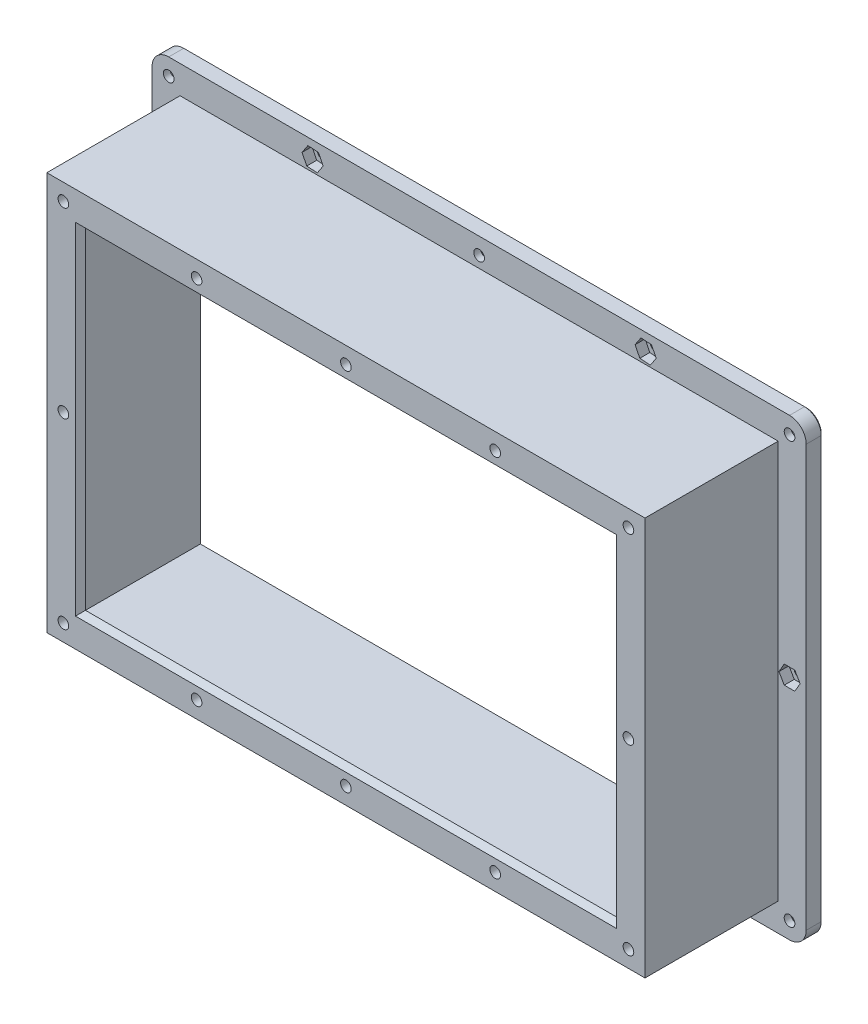
from build123d import *

# Parameters (mm, degrees)
CROQUIS1_W              = 179.6
CROQUIS1_H              = 119.6
CROQUIS1_W_2            = 176.4
CROQUIS1_H_2            = 116.4
SALIENTE_EXTRUIR1_DEPTH = 40
CROQUIS2_W              = 196.4
CROQUIS2_H              = 136.4
CROQUIS2_W_2            = 176.4
CROQUIS2_H_2            = 116.4
SALIENTE_EXTRUIR2_DEPTH = 5
SALIENTE_EXTRUIR3_DEPTH = 116.4
SALIENTE_EXTRUIR4_DEPTH = 176.4
CROQUIS5_R              = 1.6
CORTAR_EXTRUIR1_DEPTH   = 46
CORTAR_EXTRUIR2_START   = -3
CORTAR_EXTRUIR2_DEPTH   = 43
CHAFL_N1_SIZE2          = 2.121320344
CHAFL_N1_SIZE           = 3
CHAFL_N1_EDGE_2_SIZE2   = 2.121320344
CHAFL_N1_EDGE_2_SIZE    = 3
CHAFL_N1_EDGE_3_SIZE2   = 2.121320344
CHAFL_N1_EDGE_3_SIZE    = 3
CHAFL_N1_EDGE_4_SIZE2   = 2.121320344
CHAFL_N1_EDGE_4_SIZE    = 3
CROQUIS7_R              = 1.6
CORTAR_EXTRUIR3_DEPTH   = 46
CROQUIS8_R              = 2.75
CORTAR_EXTRUIR4_DEPTH   = 3
CORTAR_EXTRUIR5_START   = -2
CORTAR_EXTRUIR5_DEPTH   = 44
REDONDEO1_R             = 5
CHAFL_N2_SIZE           = 0.5


with BuildPart() as part:
    # Croquis1 → Saliente-Extruir1 (new body)
    with BuildSketch(Plane.XY):
        Rectangle(CROQUIS1_W, CROQUIS1_H)
        Rectangle(CROQUIS1_W_2, CROQUIS1_H_2, mode=Mode.SUBTRACT)
    extrude(amount=SALIENTE_EXTRUIR1_DEPTH)

    # Croquis2 → Saliente-Extruir2 (add)
    with BuildSketch(Plane(origin=(0, 0, 0), x_dir=(-1, 0, 0), z_dir=(0, 0, -1))):
        Rectangle(CROQUIS2_W, CROQUIS2_H)
        Rectangle(CROQUIS2_W_2, CROQUIS2_H_2, mode=Mode.SUBTRACT)
    extrude(amount=SALIENTE_EXTRUIR2_DEPTH)

    # Croquis3 → Saliente-Extruir3 (add)
    with BuildSketch(Plane.XZ.offset(-58.2)):
        Polygon((-88.2, 30), (-78.2, 40), (-88.2, 40), align=None)
        Polygon((88.2, 40), (88.2, 30), (78.2, 40), align=None)
    extrude(amount=SALIENTE_EXTRUIR3_DEPTH)

    # Croquis4 → Saliente-Extruir4 (add)
    with BuildSketch(Plane(origin=(-88.2, 0, 0), x_dir=(0, 0, -1), z_dir=(1, 0, 0))):
        Polygon((-40, 58.2), (-30, 58.2), (-40, 48.2), align=None)
        Polygon((-40, -48.2), (-40, -58.2), (-30, -58.2), align=None)
    extrude(amount=SALIENTE_EXTRUIR4_DEPTH)

    # Croquis5 → Cortar-Extruir1 (cut, through all)
    with BuildSketch(Plane.XY.offset(40)):
        with Locations((-84.827346257, 54.8)):
            Circle(CROQUIS5_R)
        with Locations((0, 54.8)):
            Circle(CROQUIS5_R)
        with Locations((-44.827346257, 54.8)):
            Circle(CROQUIS5_R)
        with Locations((44.827346257, 54.8)):
            Circle(CROQUIS5_R)
        with Locations((84.827346257, 54.8)):
            Circle(CROQUIS5_R)
        with Locations((84.827346257, -54.8)):
            Circle(CROQUIS5_R)
        with Locations((44.827346257, -54.8)):
            Circle(CROQUIS5_R)
        with Locations((-44.827346257, -54.8)):
            Circle(CROQUIS5_R)
        with Locations((0, -54.8)):
            Circle(CROQUIS5_R)
        with Locations((-84.827346257, -54.8)):
            Circle(CROQUIS5_R)
        with Locations((-84.827346257, 0)):
            Circle(CROQUIS5_R)
        with Locations((84.827346257, 0)):
            Circle(CROQUIS5_R)
    extrude(amount=-CORTAR_EXTRUIR1_DEPTH, mode=Mode.SUBTRACT)

    # Croquis6 → Cortar-Extruir2 (cut, through all)
    with BuildSketch(Plane.XY.offset(40).offset(CORTAR_EXTRUIR2_START)):
        Polygon((3.175426481, 54.8), (1.58771324, 57.55), (-1.58771324, 57.55), (-3.175426481, 54.8), (-1.58771324, 52.05), (1.58771324, 52.05), align=None)
        Polygon((-41.651919776, 54.8), (-43.239633017, 57.55), (-46.415059497, 57.55), (-48.002772737, 54.8), (-46.415059497, 52.05), (-43.239633017, 52.05), align=None)
        Polygon((-81.651919776, 54.8), (-83.239633017, 57.55), (-86.415059497, 57.55), (-88.002772737, 54.8), (-86.415059497, 52.05), (-83.239633017, 52.05), align=None)
        Polygon((48.002772737, 54.8), (46.415059497, 57.55), (43.239633017, 57.55), (41.651919776, 54.8), (43.239633017, 52.05), (46.415059497, 52.05), align=None)
        Polygon((88.002772737, 54.8), (86.415059497, 57.55), (83.239633017, 57.55), (81.651919776, 54.8), (83.239633017, 52.05), (86.415059497, 52.05), align=None)
        Polygon((86.415059497, -52.05), (88.002772737, -54.8), (86.415059497, -57.55), (83.239633017, -57.55), (81.651919776, -54.8), (83.239633017, -52.05), align=None)
        Polygon((46.415059497, -52.05), (48.002772737, -54.8), (46.415059497, -57.55), (43.239633017, -57.55), (41.651919776, -54.8), (43.239633017, -52.05), align=None)
        Polygon((-83.239633017, -52.05), (-81.651919776, -54.8), (-83.239633017, -57.55), (-86.415059497, -57.55), (-88.002772737, -54.8), (-86.415059497, -52.05), align=None)
        Polygon((-43.239633017, -52.05), (-41.651919776, -54.8), (-43.239633017, -57.55), (-46.415059497, -57.55), (-48.002772737, -54.8), (-46.415059497, -52.05), align=None)
        Polygon((1.58771324, -52.05), (3.175426481, -54.8), (1.58771324, -57.55), (-1.58771324, -57.55), (-3.175426481, -54.8), (-1.58771324, -52.05), align=None)
        Polygon((-81.651919776, 0), (-83.239633017, 2.75), (-86.415059497, 2.75), (-88.002772737, 0), (-86.415059497, -2.75), (-83.239633017, -2.75), align=None)
        Polygon((88.002772737, 0), (86.415059497, 2.75), (83.239633017, 2.75), (81.651919776, 0), (83.239633017, -2.75), (86.415059497, -2.75), align=None)
    extrude(amount=-CORTAR_EXTRUIR2_DEPTH, mode=Mode.SUBTRACT)

    # Chaflán1
    chafl_n1_edges = [part.edges().sort_by_distance(p)[0] for p in [
        (0, 48.2, 40),
    ]]
    chamfer(chafl_n1_edges, length=CHAFL_N1_SIZE, length2=CHAFL_N1_SIZE2)

    # Chaflán1 edge 2
    chafl_n1_edge_2_edges = [part.edges().sort_by_distance(p)[0] for p in [
        (78.2, 0, 40),
    ]]
    chamfer(chafl_n1_edge_2_edges, length=CHAFL_N1_EDGE_2_SIZE, length2=CHAFL_N1_EDGE_2_SIZE2)

    # Chaflán1 edge 3
    chafl_n1_edge_3_edges = [part.edges().sort_by_distance(p)[0] for p in [
        (-78.2, 0, 40),
    ]]
    chamfer(chafl_n1_edge_3_edges, length=CHAFL_N1_EDGE_3_SIZE, length2=CHAFL_N1_EDGE_3_SIZE2)

    # Chaflán1 edge 4
    chafl_n1_edge_4_edges = [part.edges().sort_by_distance(p)[0] for p in [
        (0, -48.2, 40),
    ]]
    chamfer(chafl_n1_edge_4_edges, length=CHAFL_N1_EDGE_4_SIZE, length2=CHAFL_N1_EDGE_4_SIZE2)

    # Croquis7 → Cortar-Extruir3 (cut, through all)
    with BuildSketch(Plane(origin=(0, 0, -5), x_dir=(-1, 0, 0), z_dir=(0, 0, -1))):
        with Locations((0, 63.2)):
            Circle(CROQUIS7_R)
        with Locations((93.2, 63.2)):
            Circle(CROQUIS7_R)
        with Locations((93.2, 0)):
            Circle(CROQUIS7_R)
        with Locations((50, 63.2)):
            Circle(CROQUIS7_R)
        with Locations((-50, 63.2)):
            Circle(CROQUIS7_R)
        with Locations((-93.2, 63.2)):
            Circle(CROQUIS7_R)
        with Locations((-93.2, 0)):
            Circle(CROQUIS7_R)
        with Locations((-93.2, -63.2)):
            Circle(CROQUIS7_R)
        with Locations((-50, -63.2)):
            Circle(CROQUIS7_R)
        with Locations((50, -63.2)):
            Circle(CROQUIS7_R)
        with Locations((93.2, -63.2)):
            Circle(CROQUIS7_R)
        with Locations((0, -63.2)):
            Circle(CROQUIS7_R)
    extrude(amount=-CORTAR_EXTRUIR3_DEPTH, mode=Mode.SUBTRACT)

    # Croquis8 → Cortar-Extruir4 (cut)
    with BuildSketch(Plane(origin=(0, 0, -5), x_dir=(-1, 0, 0), z_dir=(0, 0, -1))):
        with Locations((-93.2, 63.2)):
            Circle(CROQUIS8_R)
        with Locations((0, 63.2)):
            Circle(CROQUIS8_R)
        with Locations((93.2, 63.2)):
            Circle(CROQUIS8_R)
        with Locations((93.2, -63.2)):
            Circle(CROQUIS8_R)
        with Locations((0, -63.2)):
            Circle(CROQUIS8_R)
        with Locations((-93.2, -63.2)):
            Circle(CROQUIS8_R)
    extrude(amount=-CORTAR_EXTRUIR4_DEPTH, mode=Mode.SUBTRACT)

    # Croquis9 → Cortar-Extruir5 (cut, through all)
    with BuildSketch(Plane(origin=(0, 0, -5), x_dir=(-1, 0, 0), z_dir=(0, 0, -1)).offset(CORTAR_EXTRUIR5_START)):
        Polygon((-46.830853209, 63.399604482), (-48.588289157, 66.044363871), (-51.757435948, 65.844759388), (-53.169146791, 63.000395518), (-51.411710843, 60.355636129), (-48.242564052, 60.555240612), align=None)
        Polygon((53.169146791, 63.399604482), (51.411710843, 66.044363871), (48.242564052, 65.844759388), (46.830853209, 63.000395518), (48.588289157, 60.355636129), (51.757435948, 60.555240612), align=None)
        Polygon((53.169146791, -63.399604482), (51.757435948, -60.555240612), (48.588289157, -60.355636129), (46.830853209, -63.000395518), (48.242564052, -65.844759388), (51.411710843, -66.044363871), align=None)
        Polygon((-46.96440699, -62.268062012), (-49.289285467, -60.105130344), (-52.324878477, -61.037068332), (-53.03559301, -64.131937988), (-50.710714533, -66.294869656), (-47.675121523, -65.362931668), align=None)
        Polygon((96.375426481, 0), (94.78771324, 2.75), (91.61228676, 2.75), (90.024573519, 0), (91.61228676, -2.75), (94.78771324, -2.75), align=None)
        Polygon((-90.024573519, 0), (-91.61228676, 2.75), (-94.78771324, 2.75), (-96.375426481, 0), (-94.78771324, -2.75), (-91.61228676, -2.75), align=None)
    extrude(amount=-CORTAR_EXTRUIR5_DEPTH, mode=Mode.SUBTRACT)

    # Redondeo1
    redondeo1_edges = [part.edges().sort_by_distance(p)[0] for p in [
        (-98.2, -68.2, -2.5),
        (-98.2, 68.2, -2.5),
        (98.2, 68.2, -2.5),
        (98.2, -68.2, -2.5),
    ]]
    fillet(redondeo1_edges, radius=REDONDEO1_R)

    # Chaflán2
    chafl_n2_edges = [part.edges().sort_by_distance(p)[0] for p in [
        (-88.2, 0, -5),
        (0, 58.2, -5),
        (88.2, 0, -5),
        (0, -58.2, -5),
        (51.6, -63.2, -5),
        (94.8, 0, -5),
        (51.6, 63.2, -5),
        (-48.4, 63.2, -5),
        (-91.6, 0, -5),
        (-48.4, -63.2, -5),
        (95.95, -63.2, -5),
        (2.75, -63.2, -5),
        (-90.45, -63.2, -5),
        (-90.45, 63.2, -5),
        (2.75, 63.2, -5),
        (95.95, 63.2, -5),
        (98.2, 0, -5),
        (0, 68.2, -5),
        (-98.2, 0, -5),
        (0, -68.2, -5),
        (-96.735533906, 66.735533906, -5),
        (-96.735533906, -66.735533906, -5),
        (96.735533906, -66.735533906, -5),
        (96.735533906, 66.735533906, -5),
    ]]
    chamfer(chafl_n2_edges, length=CHAFL_N2_SIZE)


solid = part.part
